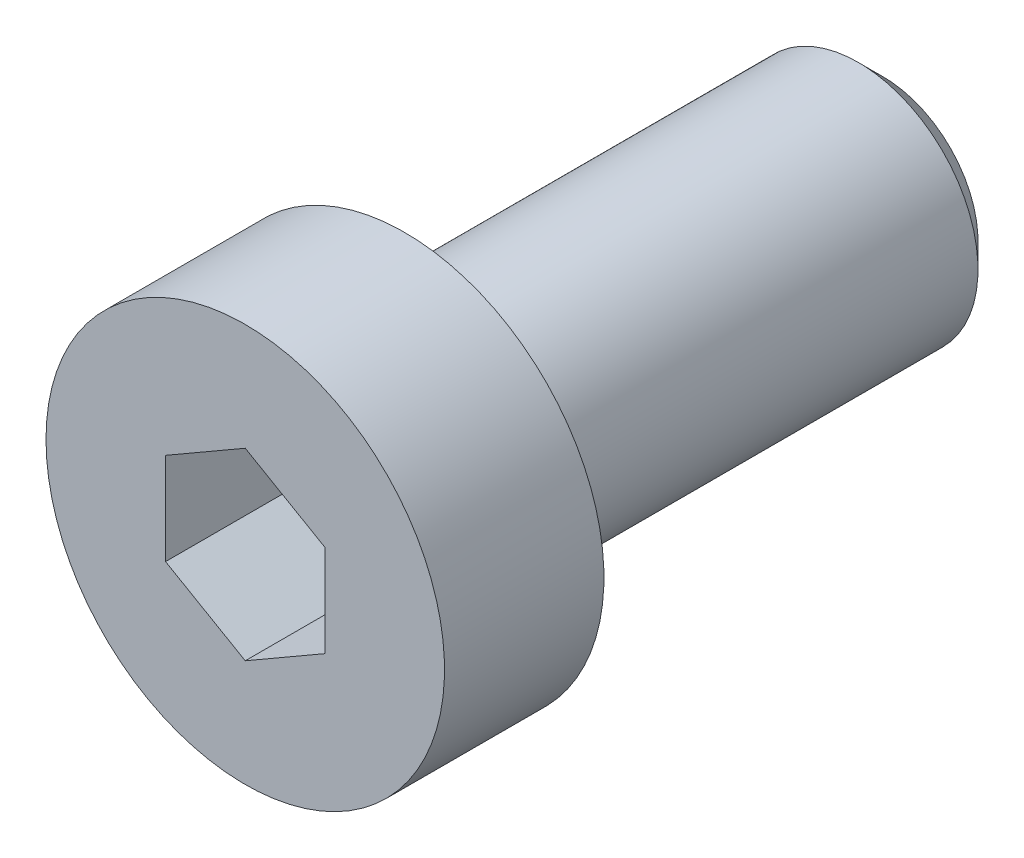
from build123d import *

# Parameters (mm, degrees)
SKETCH1_W      = 5
SKETCH1_H      = 4
SKETCH2_R      = 3
EXTRUDE1_DEPTH = 12
EXTRUDE2_DEPTH = 3
CHAMFER1_SIZE  = 0.6135
FILLET1_R      = 0.2


with BuildPart() as part:
    # Sketch1 → Revolve1 (revolve)
    with BuildSketch(Plane.XZ.offset(-21.5)):
        with Locations((-13, -2.4)):
            Rectangle(SKETCH1_W, SKETCH1_H)
    revolve(axis=Axis((-15.5, 21.5, -0.4), (0, 0, -1)))

    # Sketch2 → Extrude1 (add)
    with BuildSketch(Plane(origin=(0, 0, -4.4), x_dir=(-1, 0, 0), z_dir=(0, 0, -1))):
        with Locations((15.5, 21.5)):
            Circle(SKETCH2_R)
    extrude(amount=EXTRUDE1_DEPTH)

    # Sketch3 → Extrude2 (cut)
    with BuildSketch(Plane.XY.offset(-0.4)):
        Polygon((-17.5, 22.654700538), (-17.5, 20.345299462), (-15.5, 19.190598923), (-13.5, 20.345299462), (-13.5, 22.654700538), (-15.5, 23.809401077), align=None)
    extrude(amount=-EXTRUDE2_DEPTH, mode=Mode.SUBTRACT)

    # Sketch4 → Cut-Revolve1 (revolve, cut)
    with BuildSketch(Plane.XZ.offset(-21.5)):
        Polygon((-13.5, -3.4), (-15.5, -3.4), (-15.5, -4.127940469), align=None)
    revolve(axis=Axis((-15.5, 21.5, -3.399975), (0, 0, -1)), mode=Mode.SUBTRACT)

    # Chamfer1
    chamfer1_edges = [part.edges().sort_by_distance(p)[0] for p in [
        (-12.5, 21.5, -16.4),
    ]]
    chamfer(chamfer1_edges, length=CHAMFER1_SIZE)

    # Fillet1
    fillet1_edges = [part.edges().sort_by_distance(p)[0] for p in [
        (-12.5, 21.5, -4.4),
    ]]
    fillet(fillet1_edges, radius=FILLET1_R)


solid = part.part
